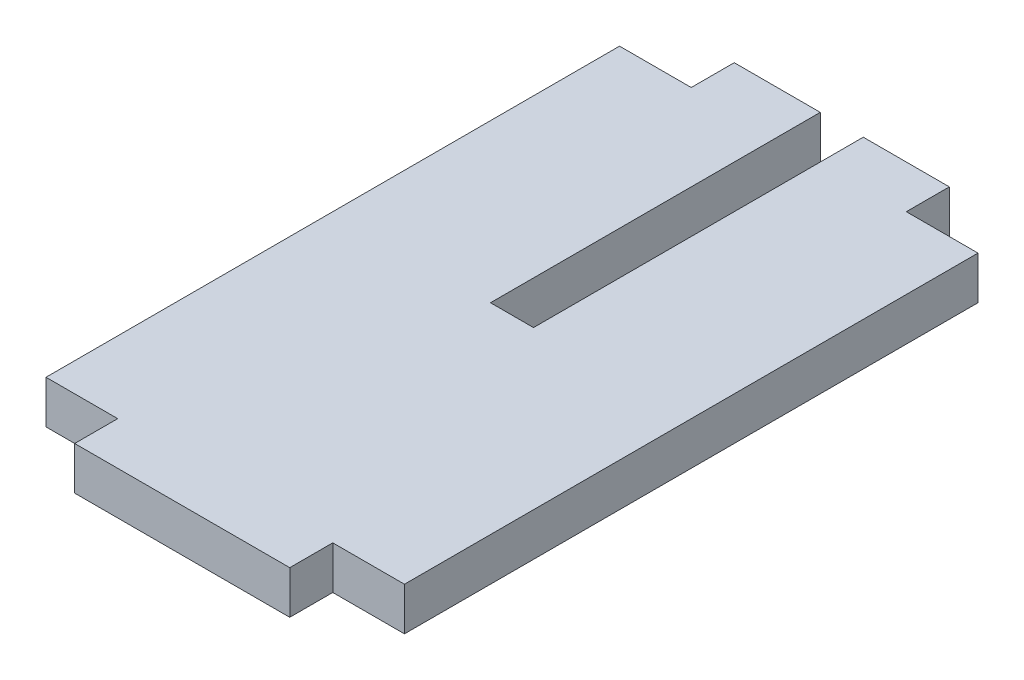
from build123d import *

# Parameters (mm, degrees)
BOSS_EXTRUDE1_DEPTH = 6
SKETCH2_W           = 6
SKETCH2_H           = 46
CUT_EXTRUDE1_DEPTH  = 7


with BuildPart() as part:
    # Sketch1 → Boss-Extrude1 (new body)
    with BuildSketch(Plane(origin=(0, 0, 0), x_dir=(1, 0, 0), z_dir=(0, 1, 0))):
        Polygon((-25, 40), (-15, 40), (-15, 46), (15, 46), (15, 40), (25, 40), (25, -40), (15, -40), (15, -46), (-15, -46), (-15, -40), (-25, -40), align=None)
    extrude(amount=BOSS_EXTRUDE1_DEPTH)

    # Sketch2 → Cut-Extrude1 (cut, through all)
    with BuildSketch(Plane(origin=(0, 6, 0), x_dir=(1, 0, 0), z_dir=(0, 1, 0))):
        with Locations((0, 23)):
            Rectangle(SKETCH2_W, SKETCH2_H)
    extrude(amount=-CUT_EXTRUDE1_DEPTH, mode=Mode.SUBTRACT)


solid = part.part
